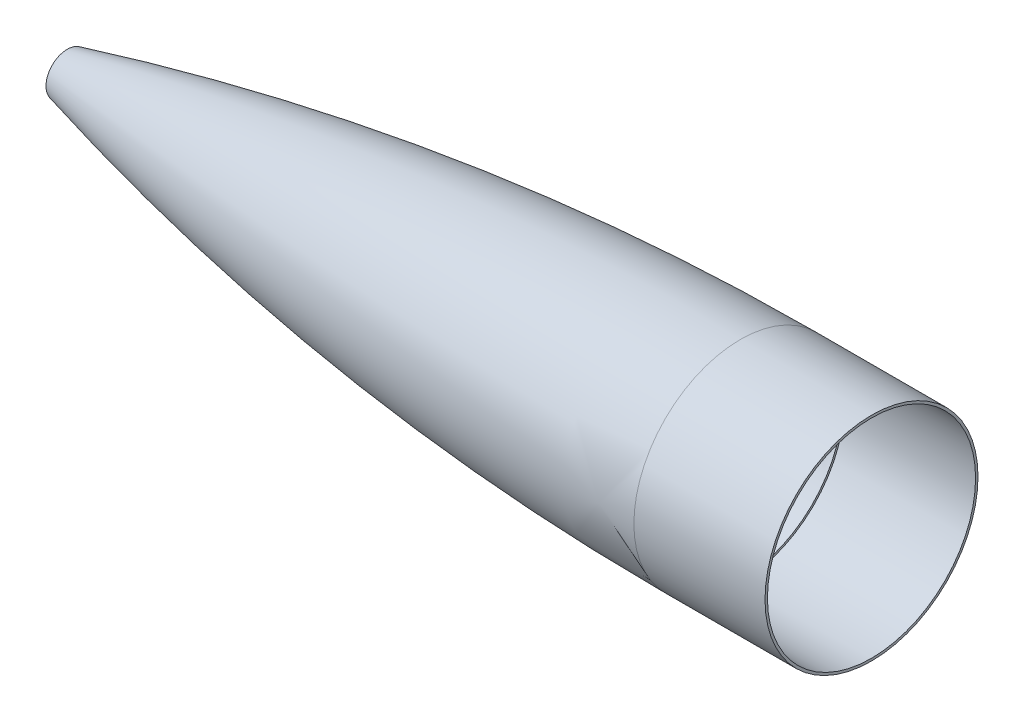
from build123d import *

# Parameters (mm, degrees)
OGIVE_SHELL_T           = -3.302
SKETCH7_R               = 76.581
CUT_EXTRUDE8_DEPTH      = 101.6
SKETCH3_W               = 5.112500062
SKETCH3_H               = 156.718
CUT_EXTRUDE5_DEPTH      = 664.371440668
CUT_EXTRUDE5_DEPTH_BACK = 664.371440668


with BuildPart() as part:
    # Ogive Sketch → Ogive Body Revolve (revolve)
    with BuildSketch(Plane.XY, mode=Mode.PRIVATE) as ogive_body_revolve_sk:
        with BuildLine():
            Line((57.15, 0), (654.05, 0))
            Line((654.05, 0), (654.05, 78.359))
            Line((654.05, 78.359), (552.45, 78.359))
            ThreePointArc((552.45, 78.359), (302.821473374, 62.613179), (57.15, 15.625315086))
            Line((57.15, 15.625315086), (57.15, 0))
        make_face()
    revolve(ogive_body_revolve_sk.sketch.rotate(Axis((0, 0, 0), (1, 0, 0)), 90), axis=Axis((0, 0, 0), (1, 0, 0)))

    # Ogive Shell
    ogive_shell_openings = [part.faces().sort_by_distance(p)[0] for p in [
        (654.05, 0, 0),
        (57.15, 0, 0),
    ]]
    offset(amount=OGIVE_SHELL_T, openings=ogive_shell_openings, kind=Kind.INTERSECTION)

    # Sketch7 → Cut-Extrude8 (cut)
    with BuildSketch(Plane(origin=(654.05, 0, 0), x_dir=(0, 0, -1), z_dir=(1, 0, 0))):
        Circle(SKETCH7_R)
    extrude(amount=-CUT_EXTRUDE8_DEPTH, mode=Mode.SUBTRACT)

    # Sketch3 → Cut-Extrude5 (cut, two sides)
    with BuildSketch(Plane(origin=(0, 0, 0), x_dir=(1, 0, 0), z_dir=(0, 1, 0))) as cut_extrude5_sk:
        with Locations((651.493749969, 0)):
            Rectangle(SKETCH3_W, SKETCH3_H)
    extrude(amount=CUT_EXTRUDE5_DEPTH, mode=Mode.SUBTRACT)
    extrude(cut_extrude5_sk.sketch, amount=-CUT_EXTRUDE5_DEPTH_BACK, mode=Mode.SUBTRACT)


solid = part.part
